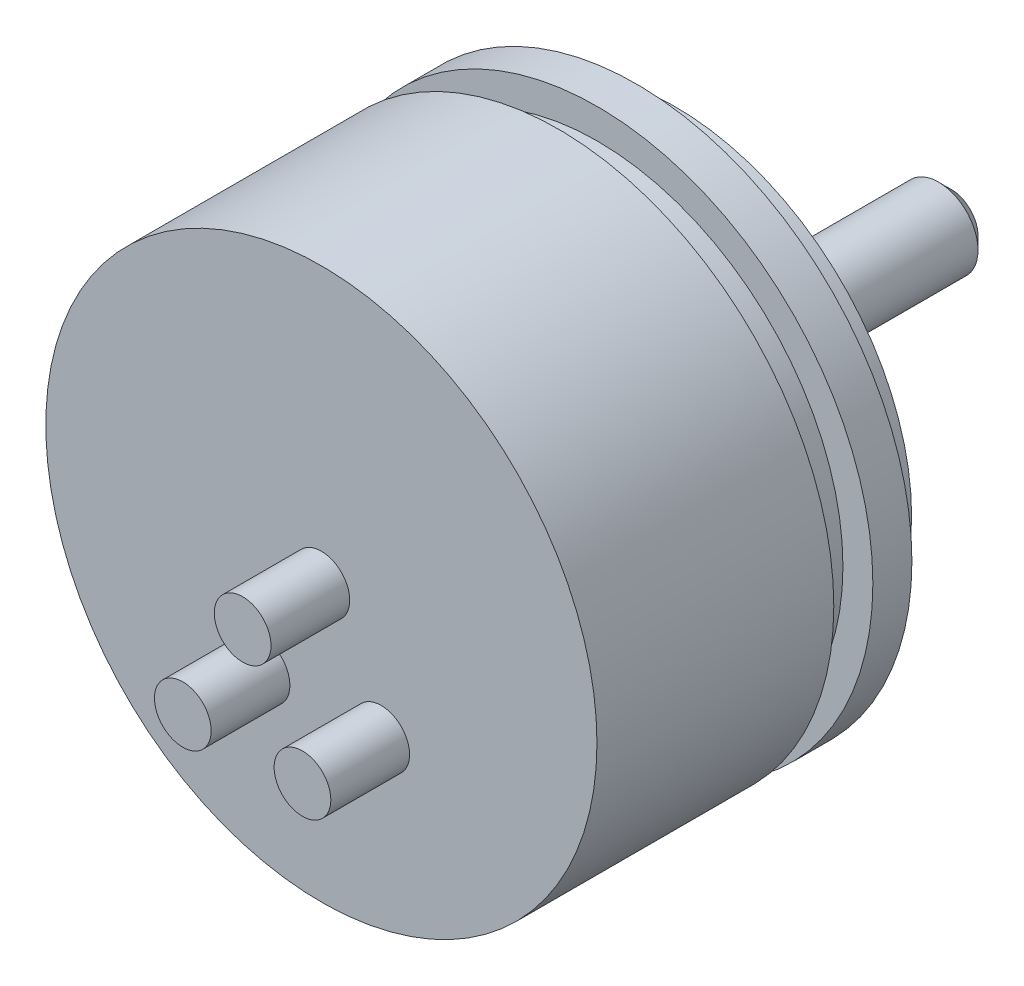
from build123d import *

# Parameters (mm, degrees)
SKETCH3_R           = 1.143
BOSS_EXTRUDE1_DEPTH = 3.175


with BuildPart() as part:
    # Sketch2 → Revolve2 (revolve)
    with BuildSketch(Plane(origin=(0, 0, 0), x_dir=(0, 0, -1), z_dir=(1, 0, 0)), mode=Mode.PRIVATE) as revolve2_sk:
        Polygon((-9.5504, 11.1125), (-9.5504, 0), (4.7244, 0), (4.7244, 1.83896), (4.7244, 9.525), (3.1496, 9.525), (3.1496, 11.1125), (1.5748, 11.1125), (1.5748, 9.906), (0, 9.906), (0, 11.1125), align=None)
        Polygon((4.7244, 1.83896), (4.7244, 0), (15.8496, 0), (15.8496, 1.07696), (15.3416, 1.58496), (5.2324, 1.58496), (5.2324, 1.83896), align=None)
    revolve(revolve2_sk.sketch.rotate(Axis((0, 0, 28.040799935), (0, 0, -1)), 90), axis=Axis((0, 0, 28.040799935), (0, 0, -1)))

    # Sketch3 → Boss-Extrude1 (add)
    with BuildSketch(Plane.XY.offset(9.5504)):
        Circle(SKETCH3_R)
        with Locations((-2.413, -4.179438599)):
            Circle(SKETCH3_R)
        with Locations((2.413, -4.179438599)):
            Circle(SKETCH3_R)
    extrude(amount=BOSS_EXTRUDE1_DEPTH)


solid = part.part
